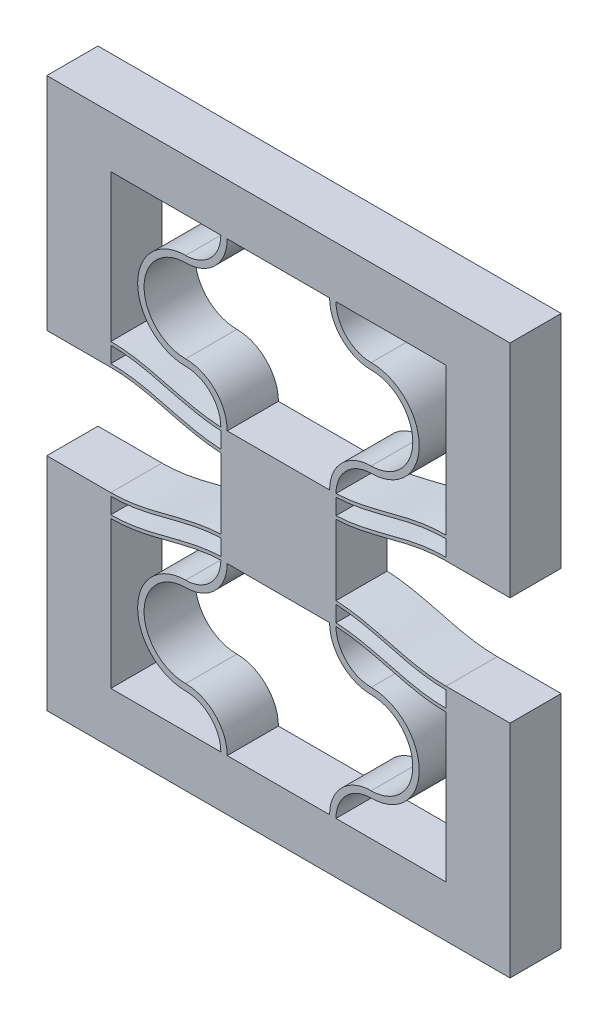
from build123d import *

# Parameters (mm, degrees)
BOSS_EXTRUDE1_DEPTH = 4
SKETCH4_W           = 1.000045189
SKETCH4_H           = 4
BOSS_EXTRUDE2_DEPTH = 1.5
SKETCH7_W           = 4
SKETCH7_H           = 4
SKETCH7_H_2         = 8.977704742
BOSS_EXTRUDE3_DEPTH = 4


with BuildPart() as part:
    # Sketch1 → Boss-Extrude1 (new body)
    with BuildSketch(Plane.XY):
        with BuildLine():
            add(Edge.make_bspline(
                [(9.600024198, 14.738852371), (9.64879558, 14.736683176), (9.87121008, 14.72551694), (10.266736815, 14.695381195), (10.945609907, 14.613464482), (11.912862218, 14.436416697), (12.867683352, 14.205371683), (13.818325908, 13.954946545), (14.560910702, 13.765886918), (15.040556936, 13.652337624), (15.487512249, 13.553576249), (15.860833974, 13.48016603), (16.233125424, 13.412776741), (16.648469385, 13.354297852), (16.969531199, 13.312975255), (17.357702161, 13.281327367), (17.634015791, 13.259907092), (17.984023618, 13.251800767), (18.127407303, 13.249999357), (18.2, 13.249999357)],
                knots=[0.522575717, 0.522575717, 0.522575717, 0.522575717, 0.522575717, 0.531389221, 0.562778459, 0.594167695, 0.645982472, 0.708760963, 0.740150204, 0.771539444, 0.784493138, 0.797446832, 0.82335422, 0.839048849, 0.854743479, 0.87043809, 0.886132702, 0.901827314, 0.917521925, 0.917521925, 0.917521925, 0.917521925, 0.917521925], degree=4))
            Line((9.600024198, 14.738852371), (9.600024198, 15.988852371))
            Line((9.600024198, 15.988852371), (8.599979009, 15.988852371))
            Line((8.599979009, 15.988852371), (8.599979009, 14.738852371))
            add(Edge.make_bspline(
                [(0, 13.249999357), (0.072592697, 13.249999357), (0.17768942, 13.251350416), (0.431351249, 13.255853931), (0.587952626, 13.265925422), (0.792239227, 13.276611465), (0.992291632, 13.293195397), (1.261917554, 13.318140508), (1.558279734, 13.354297904), (1.96155994, 13.412776691), (2.413529327, 13.492592233), (2.95145528, 13.60314404), (3.568711957, 13.748205796), (4.382247745, 13.954946561), (5.331928459, 14.205371672), (6.287354284, 14.436416704), (7.254295617, 14.613464479), (7.933286742, 14.695381197), (8.32880402, 14.72551694), (8.551209597, 14.736683176), (8.599979009, 14.738852371)],
                knots=[0.082478075, 0.082478075, 0.082478075, 0.082478075, 0.082478075, 0.098172686, 0.106019992, 0.113867298, 0.121714604, 0.12956191, 0.145256521, 0.160951151, 0.17664578, 0.202553168, 0.228460556, 0.259849796, 0.291239037, 0.354017528, 0.405832305, 0.437221541, 0.468610779, 0.477424283, 0.477424283, 0.477424283, 0.477424283, 0.477424283], degree=4))
            Line((0, 13.249999357), (-5.000000005, 13.249999357))
            Line((-5.000000005, 13.249999357), (-5.000000005, -4))
            Line((-5.000000005, -4), (23.200000005, -4))
            Line((23.200000005, -4), (23.200000005, 13.249999357))
            Line((23.200000005, 13.249999357), (18.2, 13.249999357))
        make_face()
        with BuildLine():
            Line((8.599979009, 14.488852371), (8.599979009, 13.238852371))
            add(Edge.make_bspline(
                [(0, 11.749999357), (0.072592697, 11.749999357), (0.17768942, 11.751350416), (0.431351249, 11.755853931), (0.587952626, 11.765925422), (0.792239227, 11.776611465), (0.992291632, 11.793195397), (1.261917554, 11.818140508), (1.558279734, 11.854297904), (1.96155994, 11.912776691), (2.413529327, 11.992592233), (2.95145528, 12.10314404), (3.568711957, 12.248205796), (4.382247745, 12.454946561), (5.331928459, 12.705371672), (6.287354284, 12.936416704), (7.254295617, 13.113464479), (7.933286742, 13.195381197), (8.32880402, 13.22551694), (8.551209597, 13.236683176), (8.599979009, 13.238852371)],
                knots=[0.082478075, 0.082478075, 0.082478075, 0.082478075, 0.082478075, 0.098172686, 0.106019992, 0.113867298, 0.121714604, 0.12956191, 0.145256521, 0.160951151, 0.17664578, 0.202553168, 0.228460556, 0.259849796, 0.291239037, 0.354017528, 0.405832305, 0.437221541, 0.468610779, 0.477424283, 0.477424283, 0.477424283, 0.477424283, 0.477424283], degree=4))
            Line((0, 11.749999357), (0, 12.999999357))
            add(Edge.make_bspline(
                [(0, 12.999999357), (0.072592697, 12.999999357), (0.17768942, 13.001350416), (0.431351249, 13.005853931), (0.587952626, 13.015925422), (0.792239227, 13.026611465), (0.992291632, 13.043195397), (1.261917554, 13.068140508), (1.558279734, 13.104297904), (1.96155994, 13.162776691), (2.413529327, 13.242592233), (2.95145528, 13.35314404), (3.568711957, 13.498205796), (4.382247745, 13.704946561), (5.331928459, 13.955371672), (6.287354284, 14.186416704), (7.254295617, 14.363464479), (7.933286742, 14.445381197), (8.32880402, 14.47551694), (8.551209597, 14.486683176), (8.599979009, 14.488852371)],
                knots=[0.082478075, 0.082478075, 0.082478075, 0.082478075, 0.082478075, 0.098172686, 0.106019992, 0.113867298, 0.121714604, 0.12956191, 0.145256521, 0.160951151, 0.17664578, 0.202553168, 0.228460556, 0.259849796, 0.291239037, 0.354017528, 0.405832305, 0.437221541, 0.468610779, 0.477424283, 0.477424283, 0.477424283, 0.477424283, 0.477424283], degree=4))
        make_face(mode=Mode.SUBTRACT)
        with BuildLine():
            Line((9.600024198, 13.238852371), (9.600024198, 14.488852371))
            add(Edge.make_bspline(
                [(9.600024198, 14.488852371), (9.64879558, 14.486683176), (9.87121008, 14.47551694), (10.266736815, 14.445381195), (10.945609907, 14.363464482), (11.912862218, 14.186416697), (12.867683352, 13.955371683), (13.818325908, 13.704946545), (14.560910702, 13.515886918), (15.040556936, 13.402337624), (15.487512249, 13.303576249), (15.860833974, 13.23016603), (16.233125424, 13.162776741), (16.648469385, 13.104297852), (16.969531199, 13.062975255), (17.357702161, 13.031327367), (17.634015791, 13.009907092), (17.984023618, 13.001800767), (18.127407303, 12.999999357), (18.2, 12.999999357)],
                knots=[0.522575717, 0.522575717, 0.522575717, 0.522575717, 0.522575717, 0.531389221, 0.562778459, 0.594167695, 0.645982472, 0.708760963, 0.740150204, 0.771539444, 0.784493138, 0.797446832, 0.82335422, 0.839048849, 0.854743479, 0.87043809, 0.886132702, 0.901827314, 0.917521925, 0.917521925, 0.917521925, 0.917521925, 0.917521925], degree=4))
            Line((18.2, 12.999999357), (18.2, 11.749999357))
            add(Edge.make_bspline(
                [(9.600024198, 13.238852371), (9.64879558, 13.236683176), (9.87121008, 13.22551694), (10.266736815, 13.195381195), (10.945609907, 13.113464482), (11.912862218, 12.936416697), (12.867683352, 12.705371683), (13.818325908, 12.454946545), (14.560910702, 12.265886918), (15.040556936, 12.152337624), (15.487512249, 12.053576249), (15.860833974, 11.98016603), (16.233125424, 11.912776741), (16.648469385, 11.854297852), (16.969531199, 11.812975255), (17.357702161, 11.781327367), (17.634015791, 11.759907092), (17.984023618, 11.751800767), (18.127407303, 11.749999357), (18.2, 11.749999357)],
                knots=[0.522575717, 0.522575717, 0.522575717, 0.522575717, 0.522575717, 0.531389221, 0.562778459, 0.594167695, 0.645982472, 0.708760963, 0.740150204, 0.771539444, 0.784493138, 0.797446832, 0.82335422, 0.839048849, 0.854743479, 0.87043809, 0.886132702, 0.901827314, 0.917521925, 0.917521925, 0.917521925, 0.917521925, 0.917521925], degree=4))
        make_face(mode=Mode.SUBTRACT)
        with BuildLine():
            Line((0, 0), (0, 11.499999357))
            add(Edge.make_bspline(
                [(0, 11.499999357), (0.072592697, 11.499999357), (0.17768942, 11.501350416), (0.431351249, 11.505853931), (0.587952626, 11.515925422), (0.792239227, 11.526611465), (0.992291632, 11.543195397), (1.261917554, 11.568140508), (1.558279734, 11.604297904), (1.96155994, 11.662776691), (2.413529327, 11.742592233), (2.95145528, 11.85314404), (3.568711957, 11.998205796), (4.382247745, 12.204946561), (5.331928459, 12.455371672), (6.287354284, 12.686416704), (7.254295617, 12.863464479), (7.933286742, 12.945381197), (8.32880402, 12.97551694), (8.551209597, 12.986683176), (8.599979009, 12.988852371)],
                knots=[0.082478075, 0.082478075, 0.082478075, 0.082478075, 0.082478075, 0.098172686, 0.106019992, 0.113867298, 0.121714604, 0.12956191, 0.145256521, 0.160951151, 0.17664578, 0.202553168, 0.228460556, 0.259849796, 0.291239037, 0.354017528, 0.405832305, 0.437221541, 0.468610779, 0.477424283, 0.477424283, 0.477424283, 0.477424283, 0.477424283], degree=4))
            ThreePointArc((8.599979009, 12.988852371), (7.790599968, 11.051519056), (5.850001604, 10.25))
            ThreePointArc((5.850001604, 10.25), (2.100001604, 6.5), (5.850001604, 2.75))
            ThreePointArc((5.850001604, 2.75), (7.794545252, 1.944543648), (8.600001604, 0))
            Line((8.600001604, 0), (0, 0))
        make_face(mode=Mode.SUBTRACT)
        with BuildLine():
            ThreePointArc((5.850001604, 9.75), (8.148098643, 10.701902961), (9.100001604, 13))
            ThreePointArc((9.100001604, 13), (10.051904565, 10.701902961), (12.350001604, 9.75))
            ThreePointArc((12.350001604, 9.75), (15.600001604, 6.5), (12.350001604, 3.25))
            ThreePointArc((12.350001604, 3.25), (10.051904565, 2.298097039), (9.100001604, 0))
            ThreePointArc((9.100001604, 0), (8.148098643, 2.298097039), (5.850001604, 3.25))
            ThreePointArc((5.850001604, 3.25), (2.600001604, 6.5), (5.850001604, 9.75))
        make_face(mode=Mode.SUBTRACT)
        with BuildLine():
            ThreePointArc((12.350001604, 10.25), (10.40940324, 11.051519056), (9.600024198, 12.988852371))
            add(Edge.make_bspline(
                [(9.600024198, 12.988852371), (9.64879558, 12.986683176), (9.87121008, 12.97551694), (10.266736815, 12.945381195), (10.945609907, 12.863464482), (11.912862218, 12.686416697), (12.867683352, 12.455371683), (13.818325908, 12.204946545), (14.560910702, 12.015886918), (15.040556936, 11.902337624), (15.487512249, 11.803576249), (15.860833974, 11.73016603), (16.233125424, 11.662776741), (16.648469385, 11.604297852), (16.969531199, 11.562975255), (17.357702161, 11.531327367), (17.634015791, 11.509907092), (17.984023618, 11.501800767), (18.127407303, 11.499999357), (18.2, 11.499999357)],
                knots=[0.522575717, 0.522575717, 0.522575717, 0.522575717, 0.522575717, 0.531389221, 0.562778459, 0.594167695, 0.645982472, 0.708760963, 0.740150204, 0.771539444, 0.784493138, 0.797446832, 0.82335422, 0.839048849, 0.854743479, 0.87043809, 0.886132702, 0.901827314, 0.917521925, 0.917521925, 0.917521925, 0.917521925, 0.917521925], degree=4))
            Line((18.2, 11.499999357), (18.2, 0))
            Line((18.2, 0), (9.600001604, 0))
            ThreePointArc((9.600001604, 0), (10.405457955, 1.944543648), (12.350001604, 2.75))
            ThreePointArc((12.350001604, 2.75), (16.100001604, 6.5), (12.350001604, 10.25))
        make_face(mode=Mode.SUBTRACT)
    extrude(amount=BOSS_EXTRUDE1_DEPTH)

    # Sketch4 → Boss-Extrude2 (add)
    with BuildSketch(Plane(origin=(0, 15.988852371, 0), x_dir=(1, 0, 0), z_dir=(0, 1, 0))):
        with Locations((9.100001604, -2)):
            Rectangle(SKETCH4_W, SKETCH4_H)
    extrude(amount=BOSS_EXTRUDE2_DEPTH)

    # Mirror3: part across plane


with BuildPart() as part_1:
    add(part.part)
    add(part.part.mirror(Plane.ZX.offset(17.488852371)))

    # Split2
    split(bisect_by=Plane(origin=(9.100001604, 0, 0), x_dir=(0, -1, 0), z_dir=(-1, 0, 0)), keep=Keep.BOTTOM)

    # Sketch7 → Boss-Extrude3 (add)
    with BuildSketch(Plane.ZY.offset(-9.100001604)):
        with Locations((2, 36.977704742)):
            Rectangle(SKETCH7_W, SKETCH7_H)
        with Locations((2, 17.488852371)):
            Rectangle(SKETCH7_W, SKETCH7_H_2)
        with Locations((2, -2)):
            Rectangle(SKETCH7_W, SKETCH7_H)
    extrude(amount=BOSS_EXTRUDE3_DEPTH)

    # Mirror2: part across plane


with BuildPart() as part_2:
    add(part_1.part)
    add(part_1.part.mirror(Plane.ZY.offset(-5.100001604)))


solid = part_2.part
